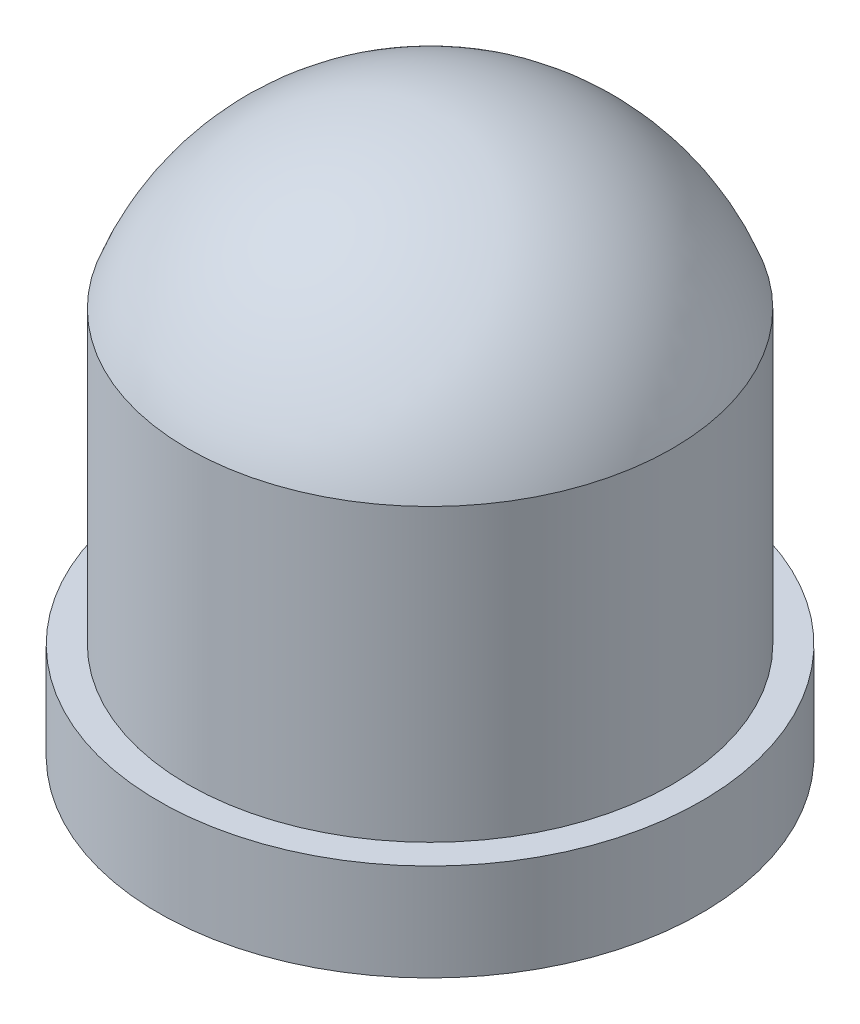
from build123d import *


with BuildPart() as part:
    # Sketch1 → Revolve1 (revolve)
    with BuildSketch(Plane(origin=(0, 0, 0), x_dir=(0, 0, -1), z_dir=(1, 0, 0))):
        with BuildLine():
            Line((0, 0), (5.6, 0))
            Line((5.6, 0), (5.6, 2))
            Line((5.6, 2), (5, 2))
            Line((5, 2), (5, 8))
            ThreePointArc((5, 8), (3.051638904, 10.538055577), (0, 11.5))
            Line((0, 11.5), (0, 0))
        make_face()
    revolve(axis=Axis((0, 0, 0), (0, 1, 0)))


solid = part.part
